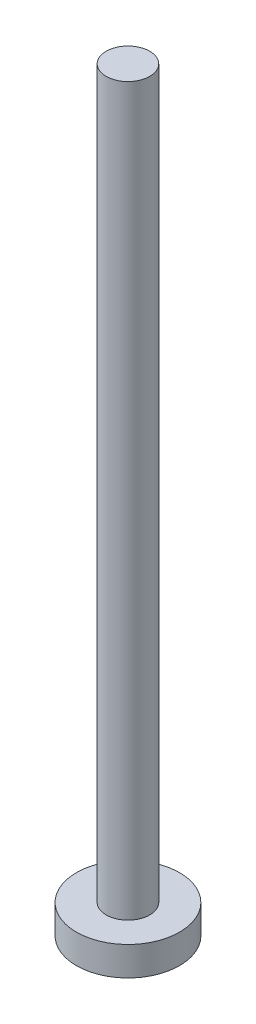
from build123d import *

# Parameters (mm, degrees)
SKETCH_1_R      = 3.55
EXTRUDE_1_DEPTH = 2
SKETCH_2_R      = 1.5
EXTRUDE_2_DEPTH = 50


with BuildPart() as part:
    # 草图1 → 凸台-拉伸1 (new body)
    with BuildSketch(Plane(origin=(0, 0, 0), x_dir=(1, 0, 0), z_dir=(0, 1, 0))):
        Circle(SKETCH_1_R)
    extrude(amount=EXTRUDE_1_DEPTH)

    # 草图2 → 凸台-拉伸2 (add)
    with BuildSketch(Plane(origin=(0, 2, 0), x_dir=(1, 0, 0), z_dir=(0, 1, 0))):
        Circle(SKETCH_2_R)
    extrude(amount=EXTRUDE_2_DEPTH)


solid = part.part
